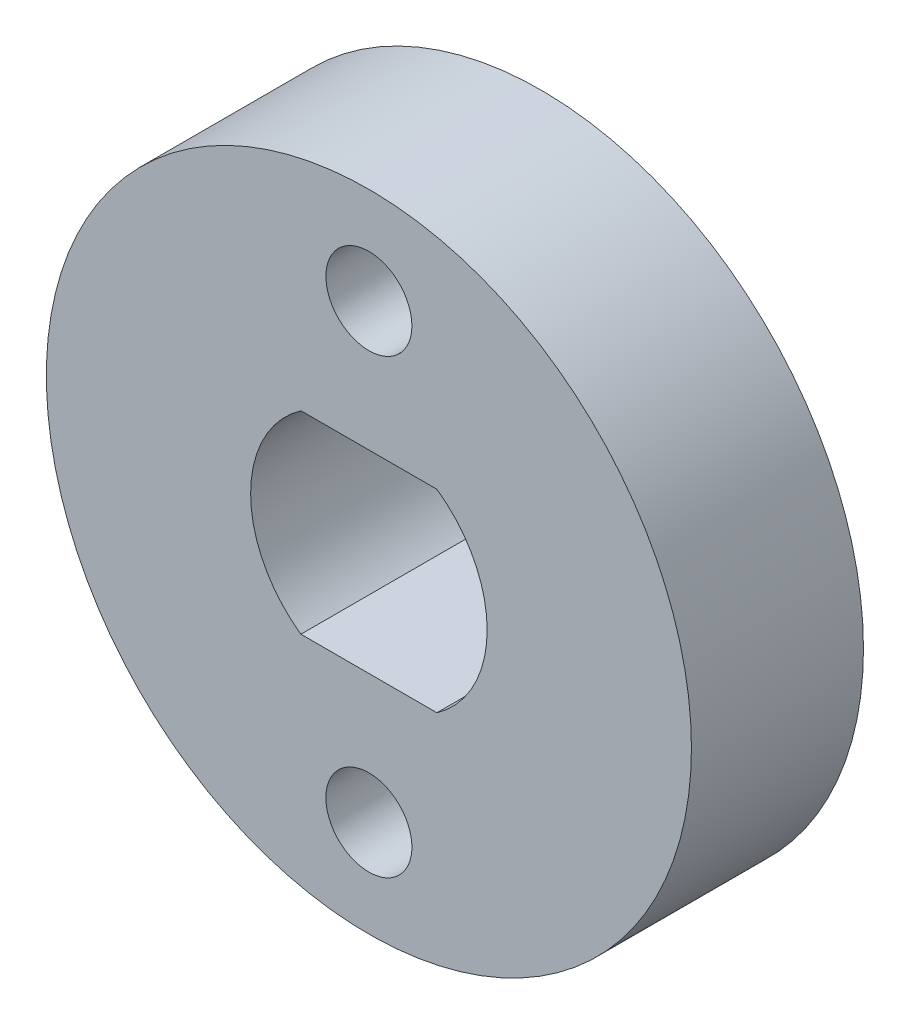
from build123d import *

# Parameters (mm, degrees)
SKETCH_1_R          = 7.5
EXTRUDE_1_DEPTH     = 4
SKETCH_4_R          = 1
CUT_EXTRUDE_2_DEPTH = 4


with BuildPart() as part:
    # Эскиз1 → Бобышка-Вытянуть1 (new body)
    with BuildSketch(Plane.XY):
        Circle(SKETCH_1_R)
    extrude(amount=EXTRUDE_1_DEPTH)

    # Эскиз4 → Вырез-Вытянуть2 (cut)
    with BuildSketch(Plane.XY.offset(4)):
        with Locations((0, 5.25)):
            Circle(SKETCH_4_R)
        with Locations((0, -5.25)):
            Circle(SKETCH_4_R)
        with BuildLine():
            Line((-1.58113883, 2.25), (1.58113883, 2.25))
            ThreePointArc((1.58113883, 2.25), (2.75, 0), (1.58113883, -2.25))
            Line((1.58113883, -2.25), (-1.58113883, -2.25))
            ThreePointArc((-1.58113883, -2.25), (-2.75, 0), (-1.58113883, 2.25))
        make_face()
    extrude(amount=-CUT_EXTRUDE_2_DEPTH, mode=Mode.SUBTRACT)


solid = part.part
